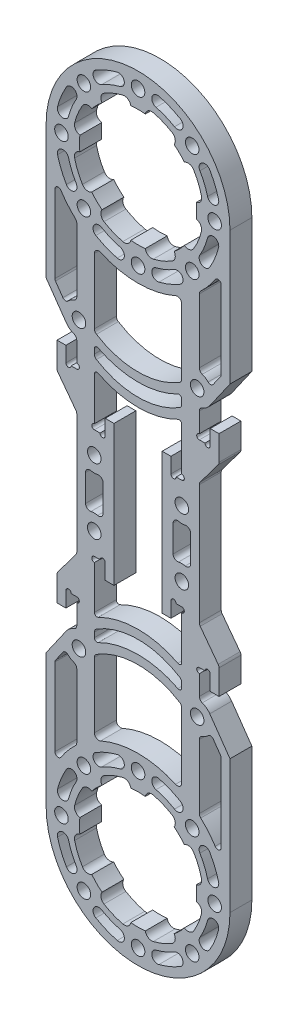
from build123d import *

# Parameters (mm, degrees)
SKETCH_1_R               = 13.4
EXTRUDE_1_DEPTH          = 2.5
SKETCH_2_R               = 0.6
CUT_EXTRUDE_1_DEPTH      = 6
SKETCH_3_R               = 1.55
CUT_EXTRUDE_2_DEPTH      = 6
SKETCH_4_R               = 1.55
CUT_EXTRUDE_3_DEPTH      = 6
FILLET_1_R               = 1
SKETCH_5_R               = 3.525
SKETCH_5_R_2             = 1.55
EXTRUDE_2_DEPTH          = 5
FILLET_2_R               = 1
CUT_EXTRUDE_4_DEPTH      = 6
PATTERN_CIRCULAR_1_COUNT = 8
MIRROR_3_COPY_1_DEPTH    = 6
MIRROR_3_COPY_2_DEPTH    = 6
MIRROR_3_COPY_3_DEPTH    = 6
MIRROR_3_COPY_4_DEPTH    = 6
MIRROR_3_COPY_5_DEPTH    = 6
MIRROR_3_COPY_6_DEPTH    = 6
MIRROR_3_COPY_7_DEPTH    = 6
CUT_EXTRUDE_5_DEPTH      = 6
PATTERN_CIRCULAR_2_COUNT = 8
MIRROR_4_COPY_1_DEPTH    = 6
MIRROR_4_COPY_2_DEPTH    = 6
MIRROR_4_COPY_3_DEPTH    = 6
MIRROR_4_COPY_4_DEPTH    = 6
MIRROR_4_COPY_5_DEPTH    = 6
MIRROR_4_COPY_6_DEPTH    = 6
MIRROR_4_COPY_7_DEPTH    = 6
EXTRUDE_3_DEPTH          = 5
SKETCH_10_R              = 0.6
CUT_EXTRUDE_6_DEPTH      = 6
FILLET_3_R               = 1
EXTRUDE_4_DEPTH          = 5
FILLET_4_R               = 0.75
EXTRUDE_5_DEPTH          = 5
PATTERN_LINEAR_1_COUNT   = 2
PATTERN_LINEAR_1_PITCH   = 5
MIRROR_8_COPY_1_DEPTH    = 5
FILLET_5_R               = 0.6
FILLET_6_R               = 1


with BuildPart() as part:
    # 草图1 → 凸台-拉伸1 (new body, symmetric)
    with BuildSketch(Plane.XY):
        with BuildLine():
            Line((-14, 51.847524158), (-14, -51.847524158))
            ThreePointArc((-14, -51.847524158), (0, -88.5), (14, -51.847524158))
            Line((14, -51.847524158), (14, 51.847524158))
            ThreePointArc((14, 51.847524158), (0, 88.5), (-14, 51.847524158))
        make_face()
        with Locations((0, -67.5)):
            Circle(SKETCH_1_R, mode=Mode.SUBTRACT)
        with Locations((0, 67.5)):
            Circle(SKETCH_1_R, mode=Mode.SUBTRACT)
        with BuildLine():
            Line((-5.5, 16.025), (-5.5, -16.025))
            Line((-5.5, -16.025), (-7.5, -16.025))
            Line((-7.5, -16.025), (-7.5, -12.525))
            Line((-7.5, -12.525), (-9.975, -12.525))
            Line((-9.975, -12.525), (-9.975, -49.020298298))
            ThreePointArc((-9.975, -49.020298298), (0, -46.5), (9.975, -49.020298298))
            Line((9.975, -49.020298298), (9.975, -12.525))
            Line((9.975, -12.525), (7.5, -12.525))
            Line((7.5, -12.525), (7.5, -16.025))
            Line((7.5, -16.025), (5.5, -16.025))
            Line((5.5, -16.025), (5.5, 16.025))
            Line((5.5, 16.025), (7.5, 16.025))
            Line((7.5, 16.025), (7.5, 12.525))
            Line((7.5, 12.525), (9.975, 12.525))
            Line((9.975, 12.525), (9.975, 49.020298298))
            ThreePointArc((9.975, 49.020298298), (0, 46.5), (-9.975, 49.020298298))
            Line((-9.975, 49.020298298), (-9.975, 12.525))
            Line((-9.975, 12.525), (-7.5, 12.525))
            Line((-7.5, 12.525), (-7.5, 16.025))
            Line((-7.5, 16.025), (-5.5, 16.025))
        make_face(mode=Mode.SUBTRACT)
    extrude(amount=EXTRUDE_1_DEPTH, both=True)

    # 草图2 → 切除-拉伸1 (cut, through all)
    with BuildSketch(Plane(origin=(0, 0, -2.5), x_dir=(-1, 0, 0), z_dir=(0, 0, -1))):
        with Locations((-8.1, 12.525)):
            Circle(SKETCH_2_R)
        with Locations((-9.975, 13.125)):
            Circle(SKETCH_2_R)
        with Locations((-9.975, -13.125)):
            Circle(SKETCH_2_R)
        with Locations((-8.1, -12.525)):
            Circle(SKETCH_2_R)
    cut_extrude_1 = extrude(amount=-CUT_EXTRUDE_1_DEPTH, mode=Mode.SUBTRACT)

    # 镜向1: 切除-拉伸1 across plane
    add(cut_extrude_1.mirror(Plane(origin=(0, 0, 0), x_dir=(0, 0, 1), z_dir=(1, 0, 0))), mode=Mode.SUBTRACT)

    # 草图3 → 切除-拉伸2 (cut, through all)
    with BuildSketch(Plane(origin=(0, 0, -2.5), x_dir=(-1, 0, 0), z_dir=(0, 0, -1))):
        with Locations((0, 85)):
            Circle(SKETCH_3_R)
        with Locations((12.374368671, 79.874368671)):
            Circle(SKETCH_3_R)
        with Locations((17.5, 67.5)):
            Circle(SKETCH_3_R)
        with Locations((12.374368671, 55.125631329)):
            Circle(SKETCH_3_R)
        with Locations((0, 50)):
            Circle(SKETCH_3_R)
        with Locations((-12.374368671, 55.125631329)):
            Circle(SKETCH_3_R)
        with Locations((-17.5, 67.5)):
            Circle(SKETCH_3_R)
        with Locations((-12.374368671, 79.874368671)):
            Circle(SKETCH_3_R)
    cut_extrude_2 = extrude(amount=-CUT_EXTRUDE_2_DEPTH, mode=Mode.SUBTRACT)

    # 镜向2: 切除-拉伸2 across plane
    add(cut_extrude_2.mirror(Plane.ZX), mode=Mode.SUBTRACT)

    # 草图4 → 切除-拉伸3 (cut, through all)
    with BuildSketch(Plane(origin=(0, 0, -2.5), x_dir=(-1, 0, 0), z_dir=(0, 0, -1))):
        with Locations((-10, 7.5)):
            Circle(SKETCH_4_R)
        with Locations((-10, -7.5)):
            Circle(SKETCH_4_R)
        with Locations((10, -7.5)):
            Circle(SKETCH_4_R)
        with Locations((10, 7.5)):
            Circle(SKETCH_4_R)
        with Locations((-13.5, 32.5)):
            Circle(SKETCH_4_R)
        with Locations((13.5, 32.5)):
            Circle(SKETCH_4_R)
        with Locations((-13.5, -32.5)):
            Circle(SKETCH_4_R)
        with Locations((13.5, -32.5)):
            Circle(SKETCH_4_R)
        with BuildLine():
            Line((-12, 4.566998125), (-12, -4.566998125))
            ThreePointArc((-12, -4.566998125), (-10, -3.95), (-8, -4.566998125))
            Line((-8, -4.566998125), (-8, 4.566998125))
            ThreePointArc((-8, 4.566998125), (-10, 3.95), (-12, 4.566998125))
        make_face()
        with BuildLine():
            Line((8, 4.566998125), (8, -4.566998125))
            ThreePointArc((8, -4.566998125), (10, -3.95), (12, -4.566998125))
            Line((12, -4.566998125), (12, 4.566998125))
            ThreePointArc((12, 4.566998125), (10, 3.95), (8, 4.566998125))
        make_face()
    extrude(amount=-CUT_EXTRUDE_3_DEPTH, mode=Mode.SUBTRACT)

    # 圆角1
    fillet_1_edges = [part.edges().sort_by_distance(p)[0] for p in [
        (12, 4.566998125, 0),
        (8, 4.566998125, 0),
        (8, -4.566998125, 0),
        (12, -4.566998125, 0),
        (-8, 4.566998125, 0),
        (-12, 4.566998125, 0),
        (-12, -4.566998125, 0),
        (-8, -4.566998125, 0),
    ]]
    fillet(fillet_1_edges, radius=FILLET_1_R)

    # 草图5 → 凸台-拉伸2 (add)
    with BuildSketch(Plane(origin=(0, 0, -2.5), x_dir=(-1, 0, 0), z_dir=(0, 0, -1))):
        with Locations((-13.5, 32.5)):
            Circle(SKETCH_5_R)
        with Locations((-13.5, 32.5)):
            Circle(SKETCH_5_R_2, mode=Mode.SUBTRACT)
        with Locations((13.5, 32.5)):
            Circle(SKETCH_5_R)
        with Locations((13.5, 32.5)):
            Circle(SKETCH_5_R_2, mode=Mode.SUBTRACT)
        with Locations((13.5, -32.5)):
            Circle(SKETCH_5_R)
        with Locations((13.5, -32.5)):
            Circle(SKETCH_5_R_2, mode=Mode.SUBTRACT)
        with Locations((-13.5, -32.5)):
            Circle(SKETCH_5_R)
        with Locations((-13.5, -32.5)):
            Circle(SKETCH_5_R_2, mode=Mode.SUBTRACT)
    extrude(amount=-EXTRUDE_2_DEPTH)

    # 圆角2
    fillet_2_edges = [part.edges().sort_by_distance(p)[0] for p in [
        (9.975, 49.020298298, 0),
        (-9.975, 49.020298298, 0),
        (-9.975, -49.020298298, 0),
        (9.975, -49.020298298, 0),
        (14, 35.989358824, 0),
        (14, 29.010641176, 0),
        (-14, 35.989358824, 0),
        (-14, 29.010641176, 0),
        (-14, -29.010641176, 0),
        (-14, -35.989358824, 0),
        (14, -29.010641176, 0),
        (14, -35.989358824, 0),
        (14, 51.847524158, 0),
        (14, -51.847524158, 0),
        (-14, -51.847524158, 0),
        (-14, 51.847524158, 0),
    ]]
    fillet(fillet_2_edges, radius=FILLET_2_R)

    # 草图6 → 切除-拉伸4 (cut, through all)
    with BuildSketch(Plane.XY.offset(2.5)):
        with BuildLine():
            ThreePointArc((-7.785228614, 80.204338449), (-8.469267265, 79.234575221), (-8.234569686, 78.071275329))
            ThreePointArc((-8.234569686, 78.071275329), (-5.127957994, 79.879985736), (-1.652300406, 80.797740536))
            ThreePointArc((-1.652300406, 80.797740536), (-2.308921399, 81.786274028), (-3.478335921, 81.988311814))
            ThreePointArc((-3.478335921, 81.988311814), (-5.701983142, 81.265805034), (-7.785228614, 80.204338449))
        make_face()
    cut_extrude_4 = extrude(amount=-CUT_EXTRUDE_4_DEPTH, mode=Mode.SUBTRACT)

    # 阵列(圆周)1: 切除-拉伸4 ×8 about axis
    pattern_circular_1_axis = Axis((0, 67.5, 0), (0, 0, 1))
    for i in range(1, PATTERN_CIRCULAR_1_COUNT):
        add(cut_extrude_4.rotate(pattern_circular_1_axis, i * 360 / PATTERN_CIRCULAR_1_COUNT), mode=Mode.SUBTRACT)

    # 镜向3: 切除-拉伸4 across plane
    add(cut_extrude_4.mirror(Plane.ZX), mode=Mode.SUBTRACT)

    # 镜向3 copy 1 sketch → 镜向3 copy 1 (cut, through all)
    with BuildSketch(Plane(origin=(47.72970773, -19.77029227, 2.5), x_dir=(0.707106781, -0.707106781, 0), z_dir=(0, 0, 1))):
        with BuildLine():
            ThreePointArc((-7.785228614, -80.204338449), (-8.469267265, -79.234575221), (-8.234569686, -78.071275329))
            ThreePointArc((-8.234569686, -78.071275329), (-5.127957994, -79.879985736), (-1.652300406, -80.797740536))
            ThreePointArc((-1.652300406, -80.797740536), (-2.308921399, -81.786274028), (-3.478335921, -81.988311814))
            ThreePointArc((-3.478335921, -81.988311814), (-5.701983142, -81.265805034), (-7.785228614, -80.204338449))
        make_face()
    extrude(amount=-MIRROR_3_COPY_1_DEPTH, mode=Mode.SUBTRACT)

    # 镜向3 copy 2 sketch → 镜向3 copy 2 (cut, through all)
    with BuildSketch(Plane(origin=(67.5, -67.5, 2.5), x_dir=(0, -1, 0), z_dir=(0, 0, 1))):
        with BuildLine():
            ThreePointArc((-7.785228614, -80.204338449), (-8.469267265, -79.234575221), (-8.234569686, -78.071275329))
            ThreePointArc((-8.234569686, -78.071275329), (-5.127957994, -79.879985736), (-1.652300406, -80.797740536))
            ThreePointArc((-1.652300406, -80.797740536), (-2.308921399, -81.786274028), (-3.478335921, -81.988311814))
            ThreePointArc((-3.478335921, -81.988311814), (-5.701983142, -81.265805034), (-7.785228614, -80.204338449))
        make_face()
    extrude(amount=-MIRROR_3_COPY_2_DEPTH, mode=Mode.SUBTRACT)

    # 镜向3 copy 3 sketch → 镜向3 copy 3 (cut, through all)
    with BuildSketch(Plane(origin=(47.72970773, -115.22970773, 2.5), x_dir=(-0.707106781, -0.707106781, 0), z_dir=(0, 0, 1))):
        with BuildLine():
            ThreePointArc((-7.785228614, -80.204338449), (-8.469267265, -79.234575221), (-8.234569686, -78.071275329))
            ThreePointArc((-8.234569686, -78.071275329), (-5.127957994, -79.879985736), (-1.652300406, -80.797740536))
            ThreePointArc((-1.652300406, -80.797740536), (-2.308921399, -81.786274028), (-3.478335921, -81.988311814))
            ThreePointArc((-3.478335921, -81.988311814), (-5.701983142, -81.265805034), (-7.785228614, -80.204338449))
        make_face()
    extrude(amount=-MIRROR_3_COPY_3_DEPTH, mode=Mode.SUBTRACT)

    # 镜向3 copy 4 sketch → 镜向3 copy 4 (cut, through all)
    with BuildSketch(Plane(origin=(0, -135, 2.5), x_dir=(-1, 0, 0), z_dir=(0, 0, 1))):
        with BuildLine():
            ThreePointArc((-7.785228614, -80.204338449), (-8.469267265, -79.234575221), (-8.234569686, -78.071275329))
            ThreePointArc((-8.234569686, -78.071275329), (-5.127957994, -79.879985736), (-1.652300406, -80.797740536))
            ThreePointArc((-1.652300406, -80.797740536), (-2.308921399, -81.786274028), (-3.478335921, -81.988311814))
            ThreePointArc((-3.478335921, -81.988311814), (-5.701983142, -81.265805034), (-7.785228614, -80.204338449))
        make_face()
    extrude(amount=-MIRROR_3_COPY_4_DEPTH, mode=Mode.SUBTRACT)

    # 镜向3 copy 5 sketch → 镜向3 copy 5 (cut, through all)
    with BuildSketch(Plane(origin=(-47.72970773, -115.22970773, 2.5), x_dir=(-0.707106781, 0.707106781, 0), z_dir=(0, 0, 1))):
        with BuildLine():
            ThreePointArc((-7.785228614, -80.204338449), (-8.469267265, -79.234575221), (-8.234569686, -78.071275329))
            ThreePointArc((-8.234569686, -78.071275329), (-5.127957994, -79.879985736), (-1.652300406, -80.797740536))
            ThreePointArc((-1.652300406, -80.797740536), (-2.308921399, -81.786274028), (-3.478335921, -81.988311814))
            ThreePointArc((-3.478335921, -81.988311814), (-5.701983142, -81.265805034), (-7.785228614, -80.204338449))
        make_face()
    extrude(amount=-MIRROR_3_COPY_5_DEPTH, mode=Mode.SUBTRACT)

    # 镜向3 copy 6 sketch → 镜向3 copy 6 (cut, through all)
    with BuildSketch(Plane(origin=(-67.5, -67.5, 2.5), x_dir=(0, 1, 0), z_dir=(0, 0, 1))):
        with BuildLine():
            ThreePointArc((-7.785228614, -80.204338449), (-8.469267265, -79.234575221), (-8.234569686, -78.071275329))
            ThreePointArc((-8.234569686, -78.071275329), (-5.127957994, -79.879985736), (-1.652300406, -80.797740536))
            ThreePointArc((-1.652300406, -80.797740536), (-2.308921399, -81.786274028), (-3.478335921, -81.988311814))
            ThreePointArc((-3.478335921, -81.988311814), (-5.701983142, -81.265805034), (-7.785228614, -80.204338449))
        make_face()
    extrude(amount=-MIRROR_3_COPY_6_DEPTH, mode=Mode.SUBTRACT)

    # 镜向3 copy 7 sketch → 镜向3 copy 7 (cut, through all)
    with BuildSketch(Plane(origin=(-47.72970773, -19.77029227, 2.5), x_dir=(0.707106781, 0.707106781, 0), z_dir=(0, 0, 1))):
        with BuildLine():
            ThreePointArc((-7.785228614, -80.204338449), (-8.469267265, -79.234575221), (-8.234569686, -78.071275329))
            ThreePointArc((-8.234569686, -78.071275329), (-5.127957994, -79.879985736), (-1.652300406, -80.797740536))
            ThreePointArc((-1.652300406, -80.797740536), (-2.308921399, -81.786274028), (-3.478335921, -81.988311814))
            ThreePointArc((-3.478335921, -81.988311814), (-5.701983142, -81.265805034), (-7.785228614, -80.204338449))
        make_face()
    extrude(amount=-MIRROR_3_COPY_7_DEPTH, mode=Mode.SUBTRACT)

    # 草图7 → 切除-拉伸5 (cut, through all)
    with BuildSketch(Plane.XY.offset(2.5)):
        with BuildLine():
            ThreePointArc((-18.394805167, 62.742779923), (-17.553711118, 60.229014785), (-16.370954048, 57.856771104))
            ThreePointArc((-16.370954048, 57.856771104), (-14.591036268, 57.396453067), (-14.130718231, 59.176370847))
            ThreePointArc((-14.130718231, 59.176370847), (-15.151624333, 61.223991709), (-15.877621302, 63.393767934))
            ThreePointArc((-15.877621302, 63.393767934), (-17.46170724, 64.326865861), (-18.394805167, 62.742779923))
        make_face()
    cut_extrude_5 = extrude(amount=-CUT_EXTRUDE_5_DEPTH, mode=Mode.SUBTRACT)

    # 阵列(圆周)2: 切除-拉伸5 ×8 about axis
    pattern_circular_2_axis = Axis((0, 67.5, 0), (0, 0, 1))
    for i in range(1, PATTERN_CIRCULAR_2_COUNT):
        add(cut_extrude_5.rotate(pattern_circular_2_axis, i * 360 / PATTERN_CIRCULAR_2_COUNT), mode=Mode.SUBTRACT)

    # 镜向4: 切除-拉伸5 across plane
    add(cut_extrude_5.mirror(Plane.ZX), mode=Mode.SUBTRACT)

    # 镜向4 copy 1 sketch → 镜向4 copy 1 (cut, through all)
    with BuildSketch(Plane(origin=(47.72970773, -19.77029227, 2.5), x_dir=(0.707106781, -0.707106781, 0), z_dir=(0, 0, 1))):
        with BuildLine():
            ThreePointArc((-18.394805167, -62.742779923), (-17.553711118, -60.229014785), (-16.370954048, -57.856771104))
            ThreePointArc((-16.370954048, -57.856771104), (-14.591036268, -57.396453067), (-14.130718231, -59.176370847))
            ThreePointArc((-14.130718231, -59.176370847), (-15.151624333, -61.223991709), (-15.877621302, -63.393767934))
            ThreePointArc((-15.877621302, -63.393767934), (-17.46170724, -64.326865861), (-18.394805167, -62.742779923))
        make_face()
    extrude(amount=-MIRROR_4_COPY_1_DEPTH, mode=Mode.SUBTRACT)

    # 镜向4 copy 2 sketch → 镜向4 copy 2 (cut, through all)
    with BuildSketch(Plane(origin=(67.5, -67.5, 2.5), x_dir=(0, -1, 0), z_dir=(0, 0, 1))):
        with BuildLine():
            ThreePointArc((-18.394805167, -62.742779923), (-17.553711118, -60.229014785), (-16.370954048, -57.856771104))
            ThreePointArc((-16.370954048, -57.856771104), (-14.591036268, -57.396453067), (-14.130718231, -59.176370847))
            ThreePointArc((-14.130718231, -59.176370847), (-15.151624333, -61.223991709), (-15.877621302, -63.393767934))
            ThreePointArc((-15.877621302, -63.393767934), (-17.46170724, -64.326865861), (-18.394805167, -62.742779923))
        make_face()
    extrude(amount=-MIRROR_4_COPY_2_DEPTH, mode=Mode.SUBTRACT)

    # 镜向4 copy 3 sketch → 镜向4 copy 3 (cut, through all)
    with BuildSketch(Plane(origin=(47.72970773, -115.22970773, 2.5), x_dir=(-0.707106781, -0.707106781, 0), z_dir=(0, 0, 1))):
        with BuildLine():
            ThreePointArc((-18.394805167, -62.742779923), (-17.553711118, -60.229014785), (-16.370954048, -57.856771104))
            ThreePointArc((-16.370954048, -57.856771104), (-14.591036268, -57.396453067), (-14.130718231, -59.176370847))
            ThreePointArc((-14.130718231, -59.176370847), (-15.151624333, -61.223991709), (-15.877621302, -63.393767934))
            ThreePointArc((-15.877621302, -63.393767934), (-17.46170724, -64.326865861), (-18.394805167, -62.742779923))
        make_face()
    extrude(amount=-MIRROR_4_COPY_3_DEPTH, mode=Mode.SUBTRACT)

    # 镜向4 copy 4 sketch → 镜向4 copy 4 (cut, through all)
    with BuildSketch(Plane(origin=(0, -135, 2.5), x_dir=(-1, 0, 0), z_dir=(0, 0, 1))):
        with BuildLine():
            ThreePointArc((-18.394805167, -62.742779923), (-17.553711118, -60.229014785), (-16.370954048, -57.856771104))
            ThreePointArc((-16.370954048, -57.856771104), (-14.591036268, -57.396453067), (-14.130718231, -59.176370847))
            ThreePointArc((-14.130718231, -59.176370847), (-15.151624333, -61.223991709), (-15.877621302, -63.393767934))
            ThreePointArc((-15.877621302, -63.393767934), (-17.46170724, -64.326865861), (-18.394805167, -62.742779923))
        make_face()
    extrude(amount=-MIRROR_4_COPY_4_DEPTH, mode=Mode.SUBTRACT)

    # 镜向4 copy 5 sketch → 镜向4 copy 5 (cut, through all)
    with BuildSketch(Plane(origin=(-47.72970773, -115.22970773, 2.5), x_dir=(-0.707106781, 0.707106781, 0), z_dir=(0, 0, 1))):
        with BuildLine():
            ThreePointArc((-18.394805167, -62.742779923), (-17.553711118, -60.229014785), (-16.370954048, -57.856771104))
            ThreePointArc((-16.370954048, -57.856771104), (-14.591036268, -57.396453067), (-14.130718231, -59.176370847))
            ThreePointArc((-14.130718231, -59.176370847), (-15.151624333, -61.223991709), (-15.877621302, -63.393767934))
            ThreePointArc((-15.877621302, -63.393767934), (-17.46170724, -64.326865861), (-18.394805167, -62.742779923))
        make_face()
    extrude(amount=-MIRROR_4_COPY_5_DEPTH, mode=Mode.SUBTRACT)

    # 镜向4 copy 6 sketch → 镜向4 copy 6 (cut, through all)
    with BuildSketch(Plane(origin=(-67.5, -67.5, 2.5), x_dir=(0, 1, 0), z_dir=(0, 0, 1))):
        with BuildLine():
            ThreePointArc((-18.394805167, -62.742779923), (-17.553711118, -60.229014785), (-16.370954048, -57.856771104))
            ThreePointArc((-16.370954048, -57.856771104), (-14.591036268, -57.396453067), (-14.130718231, -59.176370847))
            ThreePointArc((-14.130718231, -59.176370847), (-15.151624333, -61.223991709), (-15.877621302, -63.393767934))
            ThreePointArc((-15.877621302, -63.393767934), (-17.46170724, -64.326865861), (-18.394805167, -62.742779923))
        make_face()
    extrude(amount=-MIRROR_4_COPY_6_DEPTH, mode=Mode.SUBTRACT)

    # 镜向4 copy 7 sketch → 镜向4 copy 7 (cut, through all)
    with BuildSketch(Plane(origin=(-47.72970773, -19.77029227, 2.5), x_dir=(0.707106781, 0.707106781, 0), z_dir=(0, 0, 1))):
        with BuildLine():
            ThreePointArc((-18.394805167, -62.742779923), (-17.553711118, -60.229014785), (-16.370954048, -57.856771104))
            ThreePointArc((-16.370954048, -57.856771104), (-14.591036268, -57.396453067), (-14.130718231, -59.176370847))
            ThreePointArc((-14.130718231, -59.176370847), (-15.151624333, -61.223991709), (-15.877621302, -63.393767934))
            ThreePointArc((-15.877621302, -63.393767934), (-17.46170724, -64.326865861), (-18.394805167, -62.742779923))
        make_face()
    extrude(amount=-MIRROR_4_COPY_7_DEPTH, mode=Mode.SUBTRACT)

    # 草图8 → 凸台-拉伸3 (add)
    with BuildSketch(Plane.XY.offset(2.5)):
        Polygon((-14, -22.525), (-16.48, -22.525), (-16.48, -26), (-18.5, -26), (-18.5, -20), (-14, -14), align=None)
        Polygon((-14, 22.525), (-16.48, 22.525), (-16.48, 26), (-18.5, 26), (-18.5, 20), (-14, 14), align=None)
    extrude_3 = extrude(amount=-EXTRUDE_3_DEPTH)

    # 镜向6: 凸台-拉伸3 across plane
    add(extrude_3.mirror(Plane(origin=(0, 0, 0), x_dir=(0, 0, 1), z_dir=(1, 0, 0))))

    # 草图10 → 切除-拉伸6 (cut, through all)
    with BuildSketch(Plane.XY.offset(2.5)):
        with Locations((-15.88, 22.525)):
            Circle(SKETCH_10_R)
        with Locations((-14, 23.125)):
            Circle(SKETCH_10_R)
        with Locations((-15.88, -22.525)):
            Circle(SKETCH_10_R)
        with Locations((-14, -23.125)):
            Circle(SKETCH_10_R)
    cut_extrude_6 = extrude(amount=-CUT_EXTRUDE_6_DEPTH, mode=Mode.SUBTRACT)

    # 圆角3
    fillet_3_edges = [part.edges().sort_by_distance(p)[0] for p in [
        (-18.5, -20, 0),
        (-14, -14, 0),
        (-14, 14, 0),
        (-18.5, 20, 0),
        (14, -14, 0),
        (18.5, -20, 0),
        (18.5, 20, 0),
        (14, 14, 0),
    ]]
    fillet(fillet_3_edges, radius=FILLET_3_R)

    # 草图11 → 凸台-拉伸4 (add)
    with BuildSketch(Plane.XY.offset(2.5)):
        with BuildLine():
            Line((-16.387510956, -30.478143062), (-21, -37.065460096))
            Line((-21, -37.065460096), (-21, -67.5))
            ThreePointArc((-21, -67.5), (-20.493901532, -62.917424305), (-19, -58.55572809))
            Line((-19, -58.55572809), (-19, -37.696057674))
            Line((-19, -37.696057674), (-16.572061298, -34.228601857))
            ThreePointArc((-16.572061298, -34.228601857), (-17.020740072, -32.32675352), (-16.387510956, -30.478143062))
        make_face()
        with BuildLine():
            Line((-16.387510956, 30.478143062), (-21, 37.065460096))
            Line((-21, 37.065460096), (-21, 67.5))
            ThreePointArc((-21, 67.5), (-20.493901532, 62.917424305), (-19, 58.55572809))
            Line((-19, 58.55572809), (-19, 37.696057674))
            Line((-19, 37.696057674), (-16.572061298, 34.228601857))
            ThreePointArc((-16.572061298, 34.228601857), (-17.020740072, 32.32675352), (-16.387510956, 30.478143062))
        make_face()
    extrude_4 = extrude(amount=-EXTRUDE_4_DEPTH)

    # 镜向5: 凸台-拉伸4 across plane
    add(extrude_4.mirror(Plane(origin=(0, 0, 0), x_dir=(0, 0, 1), z_dir=(1, 0, 0))))

    # 圆角4
    fillet_4_edges = [part.edges().sort_by_distance(p)[0] for p in [
        (-16.572061298, -34.228601857, 0),
        (-19, -37.696057674, 0),
        (-19, -58.55572809, 0),
        (-16.572061298, 34.228601857, 0),
        (-19, 58.55572809, 0),
        (-19, 37.696057674, 0),
        (19, -58.55572809, 0),
        (19, -37.696057674, 0),
        (16.572061298, -34.228601857, 0),
        (16.572061298, 34.228601857, 0),
        (19, 37.696057674, 0),
        (19, 58.55572809, 0),
    ]]
    fillet(fillet_4_edges, radius=FILLET_4_R)

    # 镜向7: 切除-拉伸6 across plane
    add(cut_extrude_6.mirror(Plane(origin=(0, 0, 0), x_dir=(0, 0, 1), z_dir=(1, 0, 0))), mode=Mode.SUBTRACT)

    # 草图12 → 凸台-拉伸5 (add)
    with BuildSketch(Plane(origin=(0, 0, -2.5), x_dir=(-1, 0, 0), z_dir=(0, 0, -1))):
        with BuildLine():
            Line((9.975, -24.608370071), (9.975, -26.95998466))
            ThreePointArc((9.975, -26.95998466), (0, -23.943287867), (-9.975, -26.95998466))
            Line((-9.975, -26.95998466), (-9.975, -24.608370071))
            ThreePointArc((-9.975, -24.608370071), (0, -21.943287867), (9.975, -24.608370071))
        make_face()
    extrude_5 = extrude(amount=-EXTRUDE_5_DEPTH)

    # 阵列(线性)1: 凸台-拉伸5 ×2
    with Locations(*[(0, -i * PATTERN_LINEAR_1_PITCH, 0) for i in range(1, PATTERN_LINEAR_1_COUNT)]):
        add(extrude_5)

    # 镜向8: 凸台-拉伸5 across plane
    add(extrude_5.mirror(Plane.ZX))

    # 镜向8 copy 1 sketch → 镜向8 copy 1 (add)
    with BuildSketch(Plane(origin=(0, 5, -2.5), x_dir=(-1, 0, 0), z_dir=(0, 0, -1))):
        with BuildLine():
            Line((9.975, 24.608370071), (9.975, 26.95998466))
            ThreePointArc((9.975, 26.95998466), (0, 23.943287867), (-9.975, 26.95998466))
            Line((-9.975, 26.95998466), (-9.975, 24.608370071))
            ThreePointArc((-9.975, 24.608370071), (0, 21.943287867), (9.975, 24.608370071))
        make_face()
    extrude(amount=-MIRROR_8_COPY_1_DEPTH)

    # 圆角5
    fillet_5_edges = [part.edges().sort_by_distance(p)[0] for p in [
        (9.975, -24.608370071, 0),
        (-9.975, -24.608370071, 0),
        (9.975, -29.608370071, 0),
        (-9.975, -29.608370071, 0),
        (-9.975, 24.608370071, 0),
        (9.975, 24.608370071, 0),
        (-9.975, 29.608370071, 0),
        (9.975, 29.608370071, 0),
    ]]
    fillet(fillet_5_edges, radius=FILLET_5_R)

    # 圆角6
    fillet_6_edges = [part.edges().sort_by_distance(p)[0] for p in [
        (-9.975, -26.95998466, 0),
        (9.975, -26.95998466, 0),
        (-9.975, -31.95998466, 0),
        (9.975, -31.95998466, 0),
        (9.975, 26.95998466, 0),
        (-9.975, 26.95998466, 0),
        (9.975, 31.95998466, 0),
        (-9.975, 31.95998466, 0),
    ]]
    fillet(fillet_6_edges, radius=FILLET_6_R)


solid = part.part
